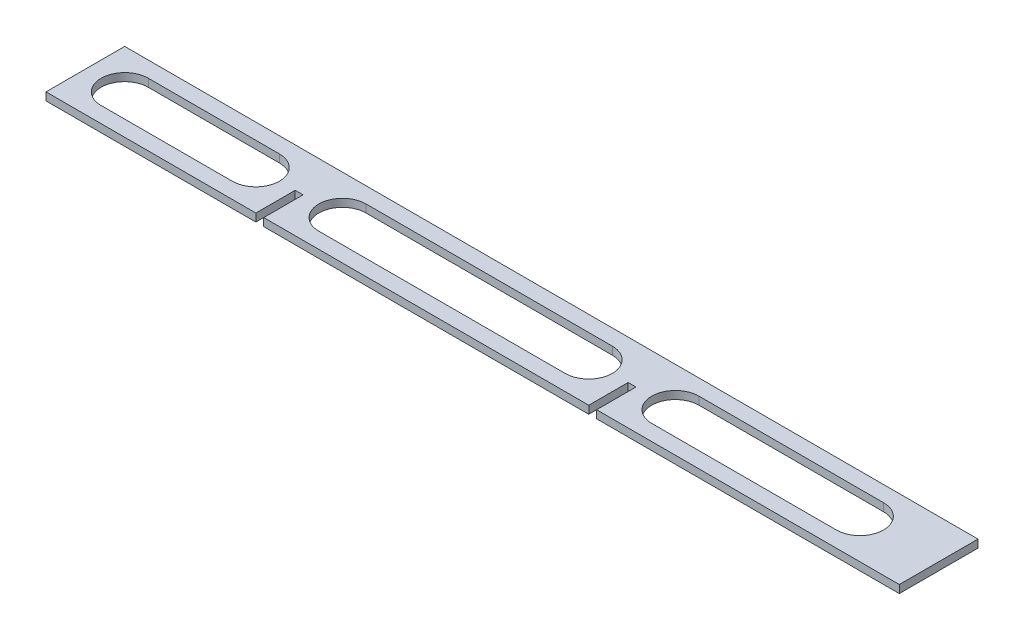
from build123d import *

# Parameters (mm, degrees)
SKETCH1_W               = 325.28
SKETCH1_H               = 30
BOSS_EXTRUDE1_DEPTH     = 3
SKETCH2_W               = 3
SKETCH2_H               = 15
CUT_EXTRUDE1_DEPTH      = 1
CUT_EXTRUDE1_DEPTH_BACK = 4
CUT_EXTRUDE3_DEPTH      = 4


with BuildPart() as part:
    # Sketch1 → Boss-Extrude1 (new body)
    with BuildSketch(Plane(origin=(0, 0, 0), x_dir=(1, 0, 0), z_dir=(0, 1, 0))):
        with Locations((162.64, 0)):
            Rectangle(SKETCH1_W, SKETCH1_H)
    extrude(amount=BOSS_EXTRUDE1_DEPTH)

    # Sketch2 → Cut-Extrude1 (cut, two sides)
    with BuildSketch(Plane(origin=(0, 3, 0), x_dir=(1, 0, 0), z_dir=(0, 1, 0))) as cut_extrude1_sk:
        with Locations((81.5, -7.5)):
            Rectangle(SKETCH2_W, SKETCH2_H)
        with Locations((208.4, -7.5)):
            Rectangle(SKETCH2_W, SKETCH2_H)
    extrude(amount=CUT_EXTRUDE1_DEPTH, mode=Mode.SUBTRACT)
    extrude(cut_extrude1_sk.sketch, amount=-CUT_EXTRUDE1_DEPTH_BACK, mode=Mode.SUBTRACT)

    # Sketch4 → Cut-Extrude3 (cut, through all)
    with BuildSketch(Plane(origin=(0, 3, 0), x_dir=(1, 0, 0), z_dir=(0, 1, 0))):
        with BuildLine():
            Line((15, 9), (65, 9))
            ThreePointArc((65, 9), (74, 0), (65, -9))
            Line((65, -9), (15, -9))
            ThreePointArc((15, -9), (6, 0), (15, 9))
        make_face()
        with BuildLine():
            Line((98, 9), (191.9, 9))
            ThreePointArc((191.9, 9), (200.9, 0), (191.9, -9))
            Line((191.9, -9), (98, -9))
            ThreePointArc((98, -9), (89, 0), (98, 9))
        make_face()
        with BuildLine():
            Line((224.9, 9), (295.28, 9))
            ThreePointArc((295.28, 9), (304.28, 0), (295.28, -9))
            Line((295.28, -9), (224.9, -9))
            ThreePointArc((224.9, -9), (215.9, 0), (224.9, 9))
        make_face()
    extrude(amount=-CUT_EXTRUDE3_DEPTH, mode=Mode.SUBTRACT)


solid = part.part
